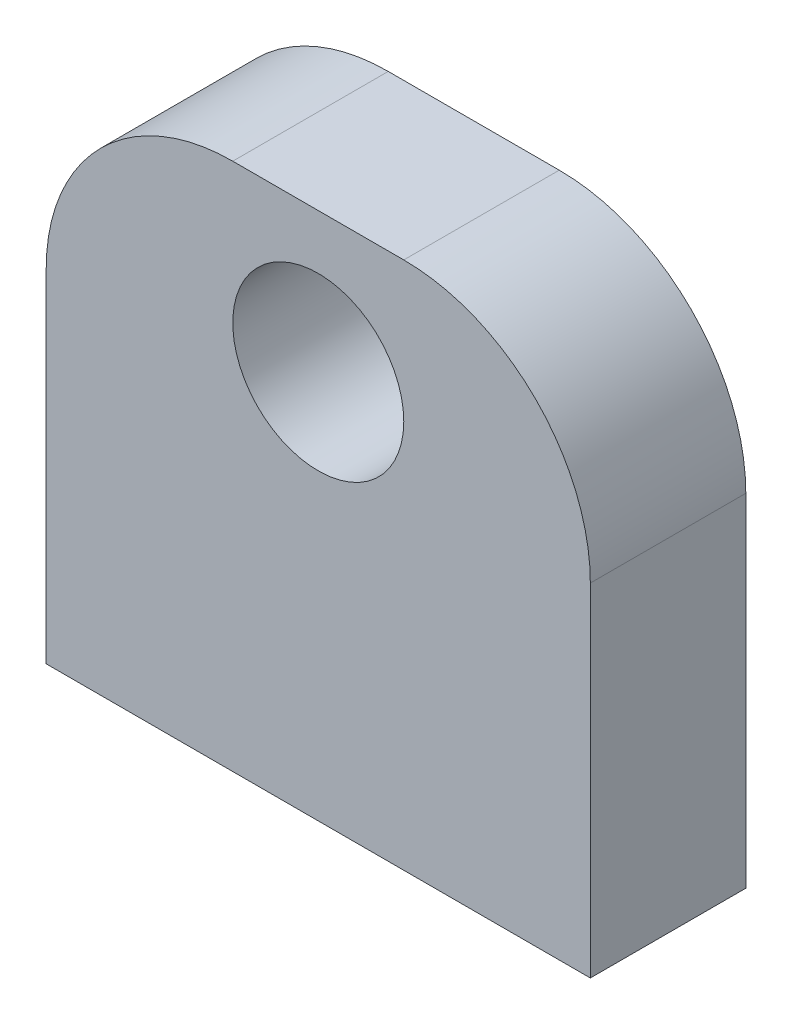
from build123d import *

# Parameters (mm, degrees)
SKETCH1_W           = 35
SKETCH1_H           = 10
BOSS_EXTRUDE1_DEPTH = 34
SKETCH2_R           = 5.5
CUT_EXTRUDE1_DEPTH  = 11
SKETCH3_R           = 1.75
CUT_EXTRUDE2_DEPTH  = 10
FILLET1_R           = 12


with BuildPart() as part:
    # Sketch1 → Boss-Extrude1 (new body)
    with BuildSketch(Plane(origin=(0, 0, 0), x_dir=(1, 0, 0), z_dir=(0, 1, 0))):
        with Locations((1.164675851, 4.144829176)):
            Rectangle(SKETCH1_W, SKETCH1_H)
    extrude(amount=BOSS_EXTRUDE1_DEPTH)

    # Sketch2 → Cut-Extrude1 (cut, through all)
    with BuildSketch(Plane.XY.offset(0.855170824)):
        with Locations((1.164675851, 25)):
            Circle(SKETCH2_R)
    extrude(amount=-CUT_EXTRUDE1_DEPTH, mode=Mode.SUBTRACT)

    # Sketch3 → Cut-Extrude2 (cut)
    with BuildSketch(Plane.XZ):
        with Locations((-8.335324149, -4.144829176)):
            Circle(SKETCH3_R)
        with Locations((10.664675851, -4.144829176)):
            Circle(SKETCH3_R)
    extrude(amount=-CUT_EXTRUDE2_DEPTH, mode=Mode.SUBTRACT)

    # Fillet1
    fillet1_edges = [part.edges().sort_by_distance(p)[0] for p in [
        (18.664675851, 34, -4.144829176),
        (-16.335324149, 34, -4.144829176),
    ]]
    fillet(fillet1_edges, radius=FILLET1_R)


solid = part.part
